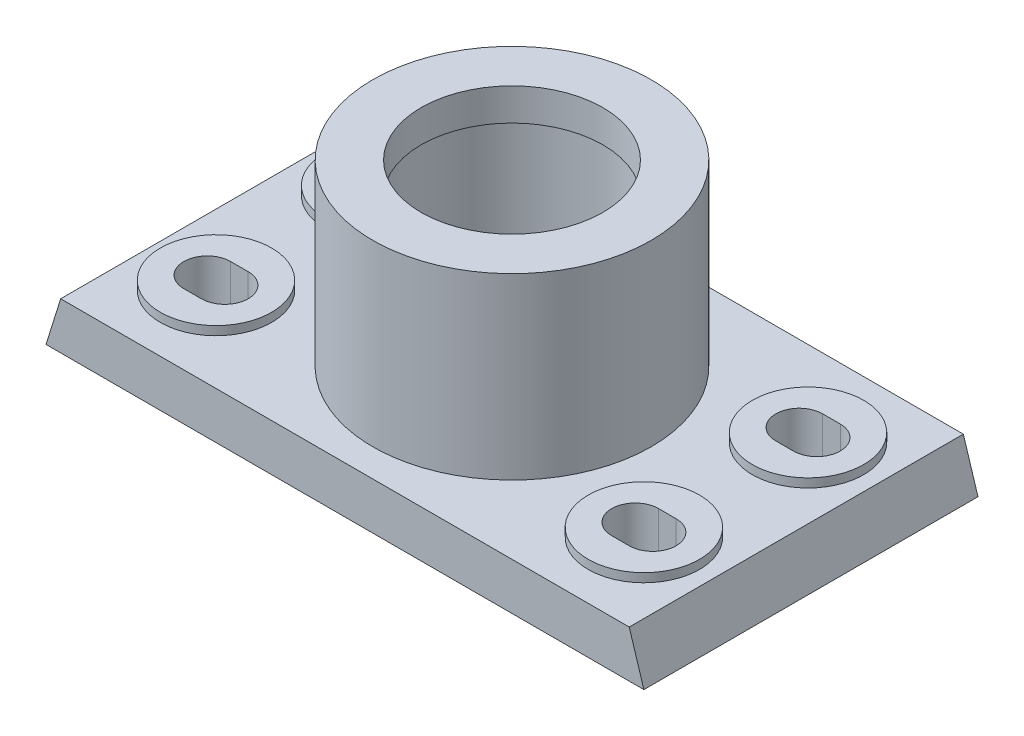
from build123d import *

# Parameters (mm, degrees)
BOSS_EXTRUDE1_DEPTH = 114
SKETCH3_W           = 82.5
SKETCH3_H           = 94
CUT_EXTRUDE1_DEPTH  = 3
CUT_EXTRUDE2_DEPTH  = 17
SKETCH5_R           = 19
BOSS_EXTRUDE2_DEPTH = 3
SKETCH6_R           = 47.5
SKETCH6_R_2         = 31
BOSS_EXTRUDE4_DEPTH = 61
SKETCH8_W           = 3
SKETCH8_H           = 35.544994967
SKETCH9_R           = 1.5
CUT_EXTRUDE3_DEPTH  = 5


with BuildPart() as part:
    # Sketch2 → Boss-Extrude1 (new body)
    with BuildSketch(Plane.XY):
        Polygon((-102, 0), (-97, 16), (97, 16), (102, 0), align=None)
    extrude(amount=-BOSS_EXTRUDE1_DEPTH)

    # Sketch3 → Cut-Extrude1 (cut)
    with BuildSketch(Plane.XZ):
        with Locations((-50.75, -57)):
            Rectangle(SKETCH3_W, SKETCH3_H)
        with Locations((50.75, -57)):
            Rectangle(SKETCH3_W, SKETCH3_H)
    extrude(amount=-CUT_EXTRUDE1_DEPTH, mode=Mode.SUBTRACT)

    # Sketch4 → Cut-Extrude2 (cut, through all)
    with BuildSketch(Plane(origin=(0, 16, 0), x_dir=(1, 0, 0), z_dir=(0, 1, 0))):
        with BuildLine():
            Line((-76, 77), (-70, 77))
            ThreePointArc((-70, 77), (-62, 85), (-70, 93))
            Line((-70, 93), (-76, 93))
            ThreePointArc((-76, 93), (-84, 85), (-76, 77))
        make_face()
        with BuildLine():
            ThreePointArc((70, 77), (62, 85), (70, 93))
            Line((70, 93), (76, 93))
            ThreePointArc((76, 93), (84, 85), (76, 77))
            Line((76, 77), (70, 77))
        make_face()
        with BuildLine():
            ThreePointArc((-70, 37), (-62, 29), (-70, 21))
            Line((-70, 21), (-76, 21))
            ThreePointArc((-76, 21), (-84, 29), (-76, 37))
            Line((-76, 37), (-70, 37))
        make_face()
        with BuildLine():
            Line((76, 37), (70, 37))
            ThreePointArc((70, 37), (62, 29), (70, 21))
            Line((70, 21), (76, 21))
            ThreePointArc((76, 21), (84, 29), (76, 37))
        make_face()
    extrude(amount=-CUT_EXTRUDE2_DEPTH, mode=Mode.SUBTRACT)

    # Sketch5 → Boss-Extrude2 (add)
    with BuildSketch(Plane(origin=(0, 16, 0), x_dir=(1, 0, 0), z_dir=(0, 1, 0))):
        with Locations(Location((-73, 85, 0), (0, 0, 180))):  # turned: the seam where the file's is
            Circle(SKETCH5_R)
        with BuildLine():
            ThreePointArc((-70, 93), (-62, 85), (-70, 77))
            Line((-70, 77), (-76, 77))
            ThreePointArc((-76, 77), (-84, 85), (-76, 93))
            Line((-76, 93), (-70, 93))
        make_face(mode=Mode.SUBTRACT)
        with Locations(Location((73, 85, 0), (0, 0, 180))):  # turned: the seam where the file's is
            Circle(SKETCH5_R)
        with BuildLine():
            ThreePointArc((76, 93), (84, 85), (76, 77))
            Line((76, 77), (70, 77))
            ThreePointArc((70, 77), (62, 85), (70, 93))
            Line((70, 93), (76, 93))
        make_face(mode=Mode.SUBTRACT)
        with Locations(Location((73, 29, 0), (0, 0, 180))):  # turned: the seam where the file's is
            Circle(SKETCH5_R)
        with BuildLine():
            ThreePointArc((70, 21), (62, 29), (70, 37))
            Line((70, 37), (76, 37))
            ThreePointArc((76, 37), (84, 29), (76, 21))
            Line((76, 21), (70, 21))
        make_face(mode=Mode.SUBTRACT)
        with Locations(Location((-73, 29, 0), (0, 0, 180))):  # turned: the seam where the file's is
            Circle(SKETCH5_R)
        with BuildLine():
            ThreePointArc((-76, 21), (-84, 29), (-76, 37))
            Line((-76, 37), (-70, 37))
            ThreePointArc((-70, 37), (-62, 29), (-70, 21))
            Line((-70, 21), (-76, 21))
        make_face(mode=Mode.SUBTRACT)
    extrude(amount=BOSS_EXTRUDE2_DEPTH)

    # Sketch6 → Boss-Extrude4 (add)
    with BuildSketch(Plane(origin=(0, 16, 0), x_dir=(1, 0, 0), z_dir=(0, 1, 0))):
        with Locations(Location((0, 57, 0), (0, 0, 180))):  # turned: the seam where the file's is
            Circle(SKETCH6_R)
        with Locations(Location((0, 57, 0), (0, 0, 180))):  # turned: the seam where the file's is
            Circle(SKETCH6_R_2, mode=Mode.SUBTRACT)
    extrude(amount=BOSS_EXTRUDE4_DEPTH)

    # Sketch8 → Cut-Revolve1 (revolve, cut)
    with BuildSketch(Plane.XY.offset(-57)):
        with Locations((-31, 48.227502517)):
            Rectangle(SKETCH8_W, SKETCH8_H)
    revolve(axis=Axis((0, 107.106199385, -57), (0, -1, 0)), mode=Mode.SUBTRACT)

    # Sketch9 → Cut-Extrude3 (cut)
    with BuildSketch(Plane(origin=(0, 16, 0), x_dir=(1, 0, 0), z_dir=(0, 1, 0))):
        with Locations(Location((-23.5, 57, 0), (0, 0, 180))):  # turned: the seam where the file's is
            Circle(SKETCH9_R)
    extrude(amount=-CUT_EXTRUDE3_DEPTH, mode=Mode.SUBTRACT)


solid = part.part
